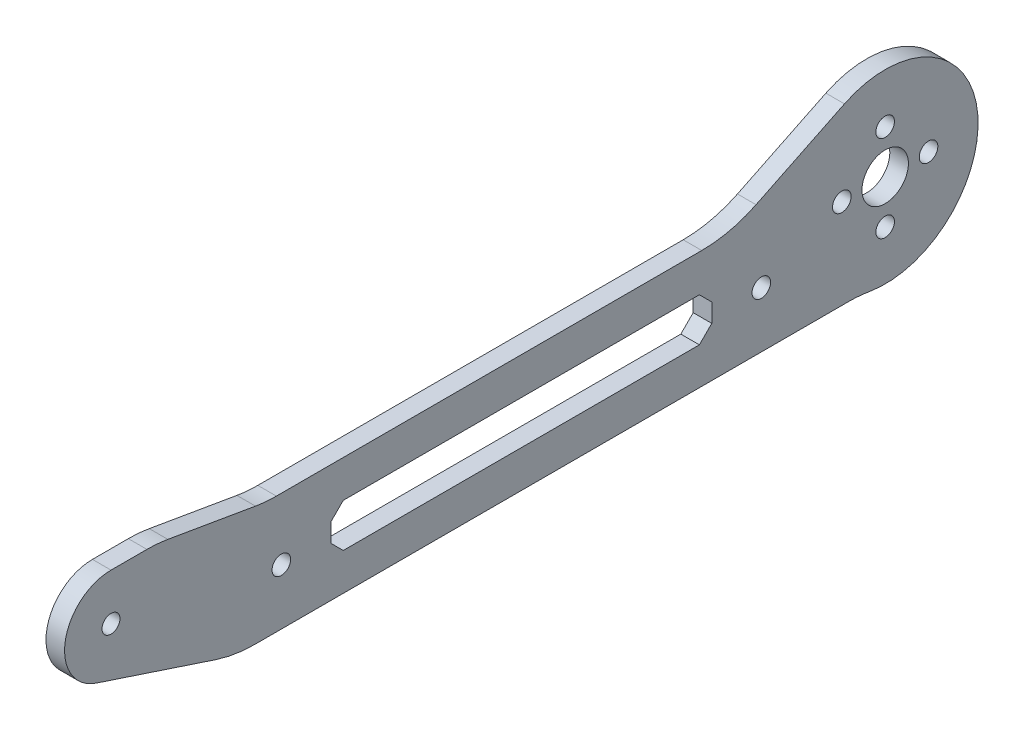
from build123d import *

# Parameters (mm, degrees)
SKETCH1_R           = 1.5
SKETCH1_R_2         = 3.75
SKETCH1_R_3         = 7.5
SKETCH1_R_4         = 1.45
BOSS_EXTRUDE1_DEPTH = 1.5
FILLET1_R           = 20


with BuildPart() as part:
    # Sketch1 → Boss-Extrude1 (new body, symmetric)
    with BuildSketch(Plane(origin=(0, 0, 0), x_dir=(0, 0, -1), z_dir=(1, 0, 0))):
        with BuildLine():
            ThreePointArc((-6.573033708, 13.483146067), (-14.928995829, -1.457766625), (-3.840572874, -14.5))
            ThreePointArc((-3.840572874, -14.5), (9.14853559, -11.887148378), (15, 0))
            ThreePointArc((15, 0), (7.9499841, 12.71997456), (-6.573033708, 13.483146067))
        make_face()
        with Locations((0, -7)):
            Circle(SKETCH1_R, mode=Mode.SUBTRACT)
        with Locations((-7, 0)):
            Circle(SKETCH1_R, mode=Mode.SUBTRACT)
        Circle(SKETCH1_R_2, mode=Mode.SUBTRACT)
        with Locations((7, 0)):
            Circle(SKETCH1_R, mode=Mode.SUBTRACT)
        with Locations((0, 7)):
            Circle(SKETCH1_R, mode=Mode.SUBTRACT)
        with BuildLine():
            Line((-127.350956164, -7.122008503), (-105, -14.5))
            Line((-105, -14.5), (-3.840572874, -14.5))
            ThreePointArc((-3.840572874, -14.5), (-14.928995829, -1.457766625), (-6.573033708, 13.483146067))
            Line((-6.573033708, 13.483146067), (-25, 4.5))
            Line((-25, 4.5), (-100, 4.5))
            Line((-100, 4.5), (-117.5, 7.5))
            Line((-117.5, 7.5), (-125, 7.5))
            ThreePointArc((-125, 7.5), (-119.696699141, 5.303300859), (-117.5, 0))
            ThreePointArc((-117.5, 0), (-120.605809018, -6.077917869), (-127.350956164, -7.122008503))
        make_face()
        with Locations((-97.5, -5.5)):
            Circle(SKETCH1_R, mode=Mode.SUBTRACT)
        Polygon((-89.5, -6.5), (-89.5, -3.5), (-87.5, -1.5), (-30, -1.5), (-28, -3.5), (-28, -6.5), (-30, -8.5), (-87.5, -8.5), align=None, mode=Mode.SUBTRACT)
        with Locations((-20, -5.5)):
            Circle(SKETCH1_R, mode=Mode.SUBTRACT)
        with Locations((-125, 0)):
            Circle(SKETCH1_R_3)
        with Locations((-125, 0)):
            Circle(SKETCH1_R_4, mode=Mode.SUBTRACT)
    extrude(amount=BOSS_EXTRUDE1_DEPTH, both=True)

    # Fillet1
    fillet1_edges = [part.edges().sort_by_distance(p)[0] for p in [
        (0.75, -14.5, 3.840572874),
        (0, -14.5, 105),
        (0, 7.5, 117.5),
        (0, 4.5, 100),
        (0, 4.5, 25),
    ]]
    fillet(fillet1_edges, radius=FILLET1_R)


solid = part.part
